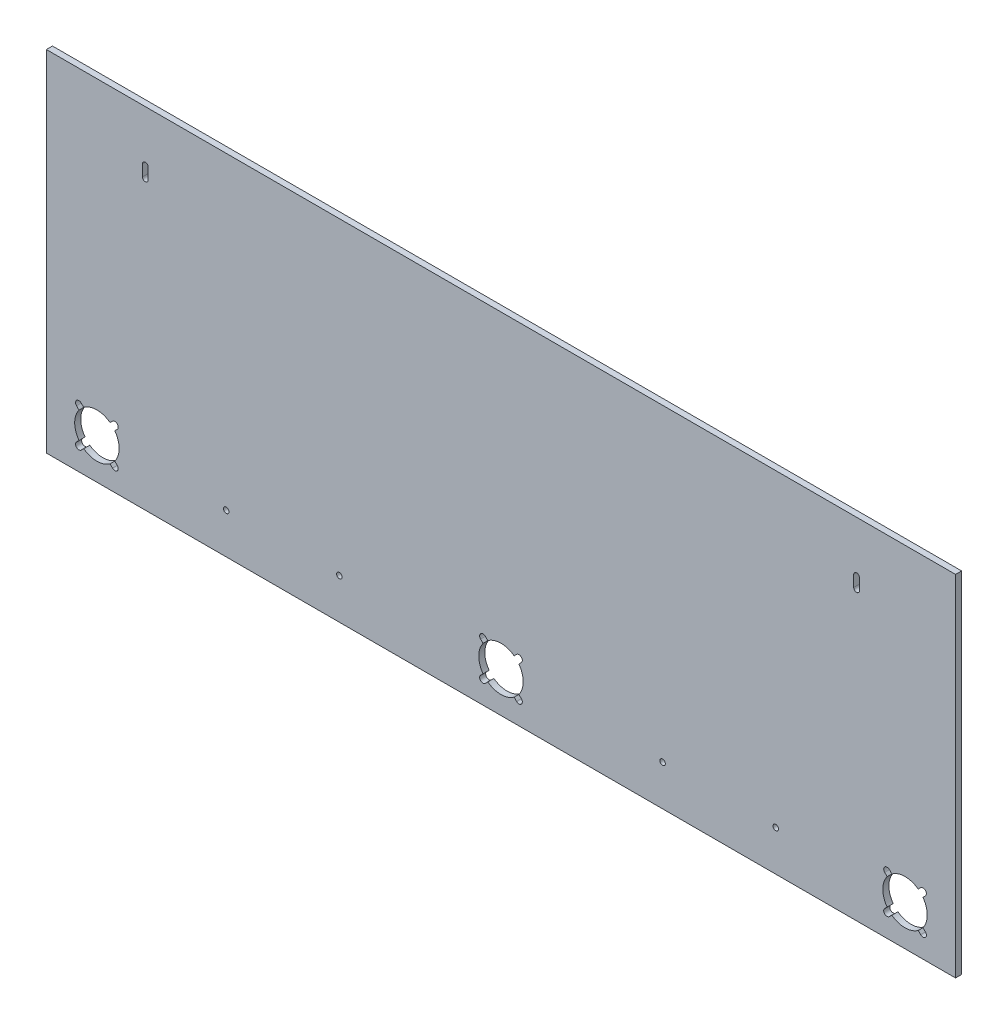
from build123d import *

# Parameters (mm, degrees)
SKETCH1_W           = 714.375
SKETCH1_H           = 274.6375
BOSS_EXTRUDE1_DEPTH = 4.7625
CUT_EXTRUDE1_DEPTH  = 5.7625
CUT_EXTRUDE3_DEPTH  = 5.7625
CUT_EXTRUDE4_REACH  = 6.763
SKETCH5_R           = 2.15265


with BuildPart() as part:
    # Sketch1 → Boss-Extrude1 (new body)
    with BuildSketch(Plane.XY):
        Rectangle(SKETCH1_W, SKETCH1_H)
    extrude(amount=BOSS_EXTRUDE1_DEPTH)

    # Sketch2 → Cut-Extrude1 (cut, through all)
    with BuildSketch(Plane.XY.offset(4.7625)):
        with BuildLine():
            Line((12.285980323, -89.570459076), (10.351389114, -91.505050285))
            ThreePointArc((10.351389114, -91.505050285), (0, -88.10625), (-10.351389114, -91.505050285))
            Line((-10.351389114, -91.505050285), (-12.285980323, -89.570459076))
            ThreePointArc((-12.285980323, -89.570459076), (-15.998290924, -89.570459076), (-15.998290924, -93.282769677))
            Line((-15.998290924, -93.282769677), (-14.063699715, -95.217360886))
            ThreePointArc((-14.063699715, -95.217360886), (-17.4625, -105.56875), (-14.063699715, -115.920139114))
            Line((-14.063699715, -115.920139114), (-15.998290924, -117.854730323))
            ThreePointArc((-15.998290924, -117.854730323), (-15.998290924, -121.567040924), (-12.285980323, -121.567040924))
            Line((-12.285980323, -121.567040924), (-10.351389114, -119.632449715))
            ThreePointArc((-10.351389114, -119.632449715), (0, -123.03125), (10.351389114, -119.632449715))
            Line((10.351389114, -119.632449715), (12.285980323, -121.567040924))
            ThreePointArc((12.285980323, -121.567040924), (15.998290924, -121.567040924), (15.998290924, -117.854730323))
            Line((15.998290924, -117.854730323), (14.063699715, -115.920139114))
            ThreePointArc((14.063699715, -115.920139114), (17.4625, -105.56875), (14.063699715, -95.217360886))
            Line((14.063699715, -95.217360886), (15.998290924, -93.282769677))
            ThreePointArc((15.998290924, -93.282769677), (15.998290924, -89.570459076), (12.285980323, -89.570459076))
        make_face()
        with BuildLine():
            Line((-305.214019677, -89.570459076), (-307.148610886, -91.505050285))
            ThreePointArc((-307.148610886, -91.505050285), (-317.5, -88.10625), (-327.851389114, -91.505050285))
            Line((-327.851389114, -91.505050285), (-329.785980323, -89.570459076))
            ThreePointArc((-329.785980323, -89.570459076), (-333.498290924, -89.570459076), (-333.498290924, -93.282769677))
            Line((-333.498290924, -93.282769677), (-331.563699715, -95.217360886))
            ThreePointArc((-331.563699715, -95.217360886), (-334.9625, -105.56875), (-331.563699715, -115.920139114))
            Line((-331.563699715, -115.920139114), (-333.498290924, -117.854730323))
            ThreePointArc((-333.498290924, -117.854730323), (-333.498290924, -121.567040924), (-329.785980323, -121.567040924))
            Line((-329.785980323, -121.567040924), (-327.851389114, -119.632449715))
            ThreePointArc((-327.851389114, -119.632449715), (-317.5, -123.03125), (-307.148610886, -119.632449715))
            Line((-307.148610886, -119.632449715), (-305.214019677, -121.567040924))
            ThreePointArc((-305.214019677, -121.567040924), (-301.501709076, -121.567040924), (-301.501709076, -117.854730323))
            Line((-301.501709076, -117.854730323), (-303.436300285, -115.920139114))
            ThreePointArc((-303.436300285, -115.920139114), (-300.0375, -105.56875), (-303.436300285, -95.217360886))
            Line((-303.436300285, -95.217360886), (-301.501709076, -93.282769677))
            ThreePointArc((-301.501709076, -93.282769677), (-301.501709076, -89.570459076), (-305.214019677, -89.570459076))
        make_face()
        with BuildLine():
            Line((329.785980323, -89.570459076), (327.851389114, -91.505050285))
            ThreePointArc((327.851389114, -91.505050285), (317.5, -88.10625), (307.148610886, -91.505050285))
            Line((307.148610886, -91.505050285), (305.214019677, -89.570459076))
            ThreePointArc((305.214019677, -89.570459076), (301.501709076, -89.570459076), (301.501709076, -93.282769677))
            Line((301.501709076, -93.282769677), (303.436300285, -95.217360886))
            ThreePointArc((303.436300285, -95.217360886), (300.0375, -105.56875), (303.436300285, -115.920139114))
            Line((303.436300285, -115.920139114), (301.501709076, -117.854730323))
            ThreePointArc((301.501709076, -117.854730323), (301.501709076, -121.567040924), (305.214019677, -121.567040924))
            Line((305.214019677, -121.567040924), (307.148610886, -119.632449715))
            ThreePointArc((307.148610886, -119.632449715), (317.5, -123.03125), (327.851389114, -119.632449715))
            Line((327.851389114, -119.632449715), (329.785980323, -121.567040924))
            ThreePointArc((329.785980323, -121.567040924), (333.498290924, -121.567040924), (333.498290924, -117.854730323))
            Line((333.498290924, -117.854730323), (331.563699715, -115.920139114))
            ThreePointArc((331.563699715, -115.920139114), (334.9625, -105.56875), (331.563699715, -95.217360886))
            Line((331.563699715, -95.217360886), (333.498290924, -93.282769677))
            ThreePointArc((333.498290924, -93.282769677), (333.498290924, -89.570459076), (329.785980323, -89.570459076))
        make_face()
    extrude(amount=-CUT_EXTRUDE1_DEPTH, mode=Mode.SUBTRACT)

    # Sketch4 → Cut-Extrude3 (cut, through all)
    with BuildSketch(Plane.XY.offset(4.7625)):
        with BuildLine():
            Line((277.1521, 88.42375), (277.1521, 97.31375))
            ThreePointArc((277.1521, 97.31375), (279.4, 99.56165), (281.6479, 97.31375))
            Line((281.6479, 97.31375), (281.6479, 88.42375))
            ThreePointArc((281.6479, 88.42375), (279.4, 86.17585), (277.1521, 88.42375))
        make_face()
        with BuildLine():
            Line((-277.1521, 88.42375), (-277.1521, 97.31375))
            ThreePointArc((-277.1521, 97.31375), (-279.4, 99.56165), (-281.6479, 97.31375))
            Line((-281.6479, 97.31375), (-281.6479, 88.42375))
            ThreePointArc((-281.6479, 88.42375), (-279.4, 86.17585), (-277.1521, 88.42375))
        make_face()
    extrude(amount=-CUT_EXTRUDE3_DEPTH, mode=Mode.SUBTRACT)

    # Sketch5 → Cut-Extrude4 (cut, up to next)
    with BuildSketch(Plane.XY.offset(4.7625), mode=Mode.PRIVATE) as cut_extrude4_sk1:
        with Locations((-127, -105.56875)):
            Circle(SKETCH5_R)
    cut_extrude4_tool1 = extrude(cut_extrude4_sk1.sketch, amount=-CUT_EXTRUDE4_REACH, mode=Mode.PRIVATE) & part.part
    add(cut_extrude4_tool1.solids().sort_by_distance((-127, -105.56875, 4.7625))[0], mode=Mode.SUBTRACT)
    # Sketch5 → Cut-Extrude4 (cut, up to next)
    with BuildSketch(Plane.XY.offset(4.7625), mode=Mode.PRIVATE) as cut_extrude4_sk2:
        with Locations((-215.9, -105.56875)):
            Circle(SKETCH5_R)
    cut_extrude4_tool2 = extrude(cut_extrude4_sk2.sketch, amount=-CUT_EXTRUDE4_REACH, mode=Mode.PRIVATE) & part.part
    add(cut_extrude4_tool2.solids().sort_by_distance((-215.9, -105.56875, 4.7625))[0], mode=Mode.SUBTRACT)
    # Sketch5 → Cut-Extrude4 (cut, up to next)
    with BuildSketch(Plane.XY.offset(4.7625), mode=Mode.PRIVATE) as cut_extrude4_sk3:
        with Locations((215.9, -105.56875)):
            Circle(SKETCH5_R)
    cut_extrude4_tool3 = extrude(cut_extrude4_sk3.sketch, amount=-CUT_EXTRUDE4_REACH, mode=Mode.PRIVATE) & part.part
    add(cut_extrude4_tool3.solids().sort_by_distance((215.9, -105.56875, 4.7625))[0], mode=Mode.SUBTRACT)
    # Sketch5 → Cut-Extrude4 (cut, up to next)
    with BuildSketch(Plane.XY.offset(4.7625), mode=Mode.PRIVATE) as cut_extrude4_sk4:
        with Locations((127, -105.56875)):
            Circle(SKETCH5_R)
    cut_extrude4_tool4 = extrude(cut_extrude4_sk4.sketch, amount=-CUT_EXTRUDE4_REACH, mode=Mode.PRIVATE) & part.part
    add(cut_extrude4_tool4.solids().sort_by_distance((127, -105.56875, 4.7625))[0], mode=Mode.SUBTRACT)


solid = part.part
